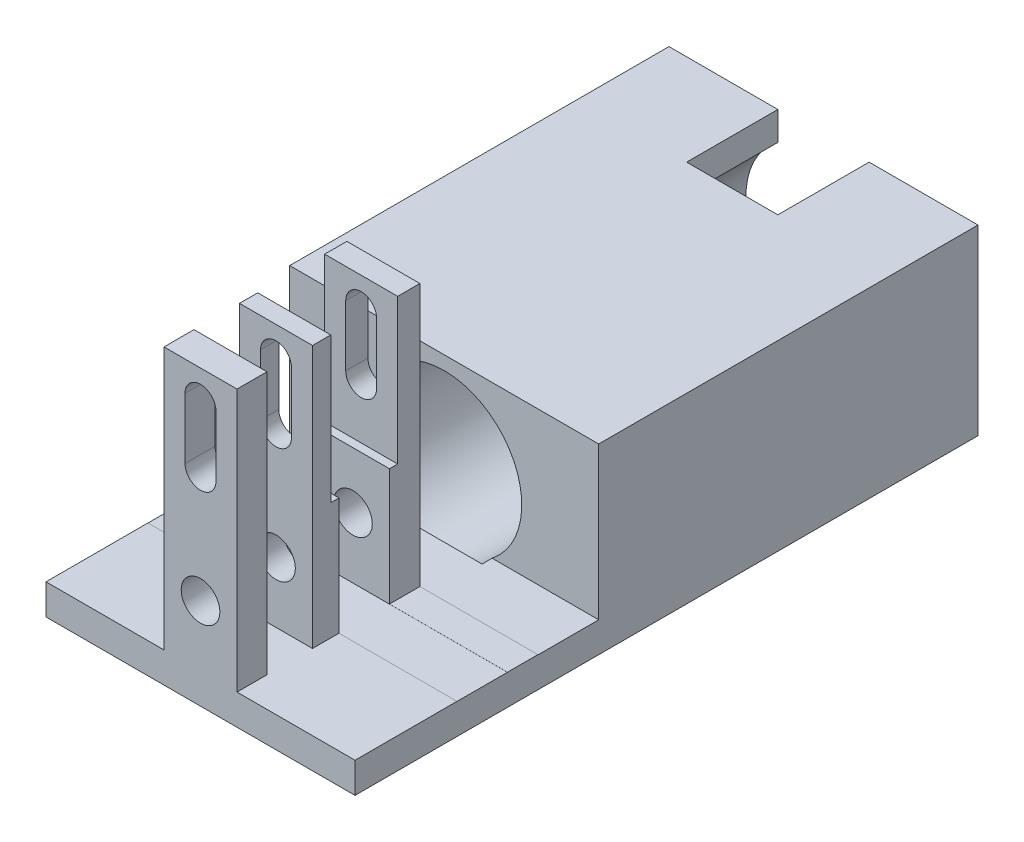
from build123d import *

# Parameters (mm, degrees)
SKETCH1_W                      = 50.8
SKETCH1_H                      = 90
MAIN_EXTRUDE_DEPTH             = 30
SKETCH2_R                      = 12.75
MOTOR_SLOT_CUT_DEPTH           = 64
SKETCH3_W                      = 8.3
SKETCH3_H                      = 25
FILLAMENT_THROUGHWAY_CUT_DEPTH = 51.8
SKETCH4_R                      = 3.175
BOTTOM_AXLE_CUT_DEPTH          = 91
SKETCH6_W                      = 50.8
SKETCH6_H                      = 4.35
SKETCH6_H_2                    = 5
TOP_FINS_EXTRUDE_DEPTH         = 18.15
TOP_AXLE_CUT_DEPTH             = 91
SKETCH8_W                      = 15
SKETCH8_H                      = 15
WIRE_HOLE_CUT_DEPTH            = 8
SKETCH9_W                      = 19.4
SKETCH9_H                      = 43.140250719
EASEOFACCESSCUT_DEPTH          = 20
SKETCH10_W                     = 25
SKETCH10_H                     = 27.637362277
BEARINGSIZECUT_DEPTH           = 5.5
SKETCH11_W                     = 10
SKETCH11_H                     = 25.030494578
RUBBER_BAND_CUT_DEPTH          = 51.8
SKETCH12_W                     = 50.8
SKETCH12_H                     = 5.009749281
BOSS_EXTRUDE1_DEPTH            = 12.41
SKETCH13_W                     = 12
SKETCH13_H                     = 4.924328521
BOSS_EXTRUDE2_DEPTH            = 43.140251
SKETCH15_R                     = 3.175
CUT_EXTRUDE1_DEPTH             = 12.41


with BuildPart() as part:
    # Sketch1 → Main Extrude (new body)
    with BuildSketch(Plane(origin=(0, 0, 0), x_dir=(1, 0, 0), z_dir=(0, 1, 0))):
        Rectangle(SKETCH1_W, SKETCH1_H)
    extrude(amount=MAIN_EXTRUDE_DEPTH)

    # Sketch2 → Motor Slot Cut (cut)
    with BuildSketch(Plane(origin=(0, 0, -45), x_dir=(-1, 0, 0), z_dir=(0, 0, -1))):
        with Locations((0, 15)):
            Circle(SKETCH2_R)
    extrude(amount=-MOTOR_SLOT_CUT_DEPTH, mode=Mode.SUBTRACT)

    # Sketch3 → Fillament Throughway cut (cut, through all)
    with BuildSketch(Plane(origin=(25.4, 0, 0), x_dir=(0, 0, -1), z_dir=(1, 0, 0))):
        with Locations((-36.5, 17.5)):
            Rectangle(SKETCH3_W, SKETCH3_H)
    extrude(amount=-FILLAMENT_THROUGHWAY_CUT_DEPTH, mode=Mode.SUBTRACT)

    # Sketch4 → Bottom Axle Cut (cut, through all)
    with BuildSketch(Plane.XY.offset(45)):
        with Locations((0, 15)):
            Circle(SKETCH4_R)
    extrude(amount=-BOTTOM_AXLE_CUT_DEPTH, mode=Mode.SUBTRACT)

    # Sketch6 → Top Fins Extrude (add)
    with BuildSketch(Plane(origin=(0, 30, 0), x_dir=(1, 0, 0), z_dir=(0, 1, 0))):
        with Locations((0, -42.825)):
            Rectangle(SKETCH6_W, SKETCH6_H)
        with Locations((0, -29.85)):
            Rectangle(SKETCH6_W, SKETCH6_H_2)
    extrude(amount=TOP_FINS_EXTRUDE_DEPTH)

    # Sketch7 → Top Axle Cut (cut, through all)
    with BuildSketch(Plane.XY.offset(45)):
        with BuildLine():
            Line((2.54, 43.275), (2.54, 33.275))
            ThreePointArc((2.54, 33.275), (0, 30.735), (-2.54, 33.275))
            Line((-2.54, 33.275), (-2.54, 43.275))
            ThreePointArc((-2.54, 43.275), (0, 45.815), (2.54, 43.275))
        make_face()
    extrude(amount=-TOP_AXLE_CUT_DEPTH, mode=Mode.SUBTRACT)

    # Sketch8 → Wire Hole Cut (cut)
    with BuildSketch(Plane(origin=(0, 30, 0), x_dir=(1, 0, 0), z_dir=(0, 1, 0))):
        with Locations((0, 37.5)):
            Rectangle(SKETCH8_W, SKETCH8_H)
    extrude(amount=-WIRE_HOLE_CUT_DEPTH, mode=Mode.SUBTRACT)

    # Sketch9 → EaseOfAccessCut (cut)
    with BuildSketch(Plane.XY.offset(45)):
        with Locations((-15.7, 26.579874641)):
            Rectangle(SKETCH9_W, SKETCH9_H)
        with Locations((15.7, 26.579874641)):
            Rectangle(SKETCH9_W, SKETCH9_H)
    extrude(amount=-EASEOFACCESSCUT_DEPTH, mode=Mode.SUBTRACT)

    # Sketch10 → BearingSizeCut (cut, symmetric)
    with BuildSketch(Plane.XY.offset(36.5)):
        with Locations((0, 38.093681139)):
            Rectangle(SKETCH10_W, SKETCH10_H)
    extrude(amount=BEARINGSIZECUT_DEPTH, both=True, mode=Mode.SUBTRACT)

    # Sketch11 → Rubber Band Cut (cut, through all)
    with BuildSketch(Plane(origin=(25.4, 0, 0), x_dir=(0, 0, -1), z_dir=(1, 0, 0))):
        with Locations((-22.35, 17.484752711)):
            Rectangle(SKETCH11_W, SKETCH11_H)
    extrude(amount=-RUBBER_BAND_CUT_DEPTH, mode=Mode.SUBTRACT)

    # Sketch12 → Boss-Extrude1 (add)
    with BuildSketch(Plane.XY.offset(45)):
        with Locations((0, 2.504874641)):
            Rectangle(SKETCH12_W, SKETCH12_H)
    extrude(amount=BOSS_EXTRUDE1_DEPTH)

    # Sketch13 → Boss-Extrude2 (add)
    with BuildSketch(Plane(origin=(0, 5.009749281, 0), x_dir=(1, 0, 0), z_dir=(0, 1, 0))):
        with Locations((0, -54.94783574)):
            Rectangle(SKETCH13_W, SKETCH13_H)
    extrude(amount=BOSS_EXTRUDE2_DEPTH)

    # Sketch15 → Cut-Extrude1 (cut)
    with BuildSketch(Plane(origin=(0, 0, 52.485671479), x_dir=(-1, 0, 0), z_dir=(0, 0, -1))):
        with Locations((0, 15)):
            Circle(SKETCH15_R)
        with BuildLine():
            Line((-2.54, 33.28), (-2.54, 43.28))
            ThreePointArc((-2.54, 43.28), (0, 45.82), (2.54, 43.28))
            Line((2.54, 43.28), (2.54, 33.28))
            ThreePointArc((2.54, 33.28), (0, 30.74), (-2.54, 33.28))
        make_face()
    extrude(amount=-CUT_EXTRUDE1_DEPTH, mode=Mode.SUBTRACT)


solid = part.part
